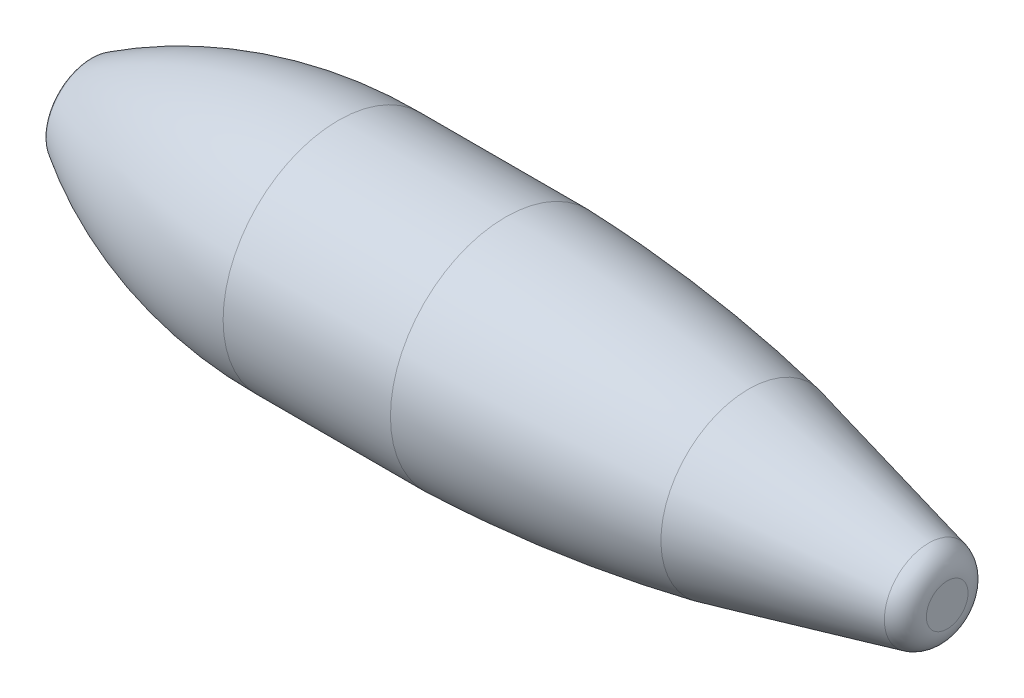
from build123d import *


with BuildPart() as part:
    # Sketch1 → Revolve1 (revolve)
    with BuildSketch(Plane.XY):
        with BuildLine():
            Line((-182.645, 14.5), (-182.645, 0))
            Line((-182.645, 0), (171.905, 0))
            Line((171.905, 0), (171.905, 8.615285742))
            ThreePointArc((171.905, 8.615285742), (169.757653906, 14.806878964), (164.237834674, 18.339373482))
            Line((164.237834674, 18.339373482), (89.705, 36.22))
            ThreePointArc((89.705, 36.22), (39.696478516, 43.963471631), (-10.775, 47.63))
            Line((-10.775, 47.63), (-79.995, 47.63))
            ThreePointArc((-79.995, 47.63), (-132.790093523, 40.554253152), (-181.597791569, 19.218913806))
            ThreePointArc((-181.597791569, 19.218913806), (-182.365435036, 18.418408121), (-182.645, 17.34512844))
            Line((-182.645, 17.34512844), (-182.645, 14.5))
        make_face()
    revolve(axis=Axis((171.905, 0, 0), (-1, 0, 0)))


solid = part.part
